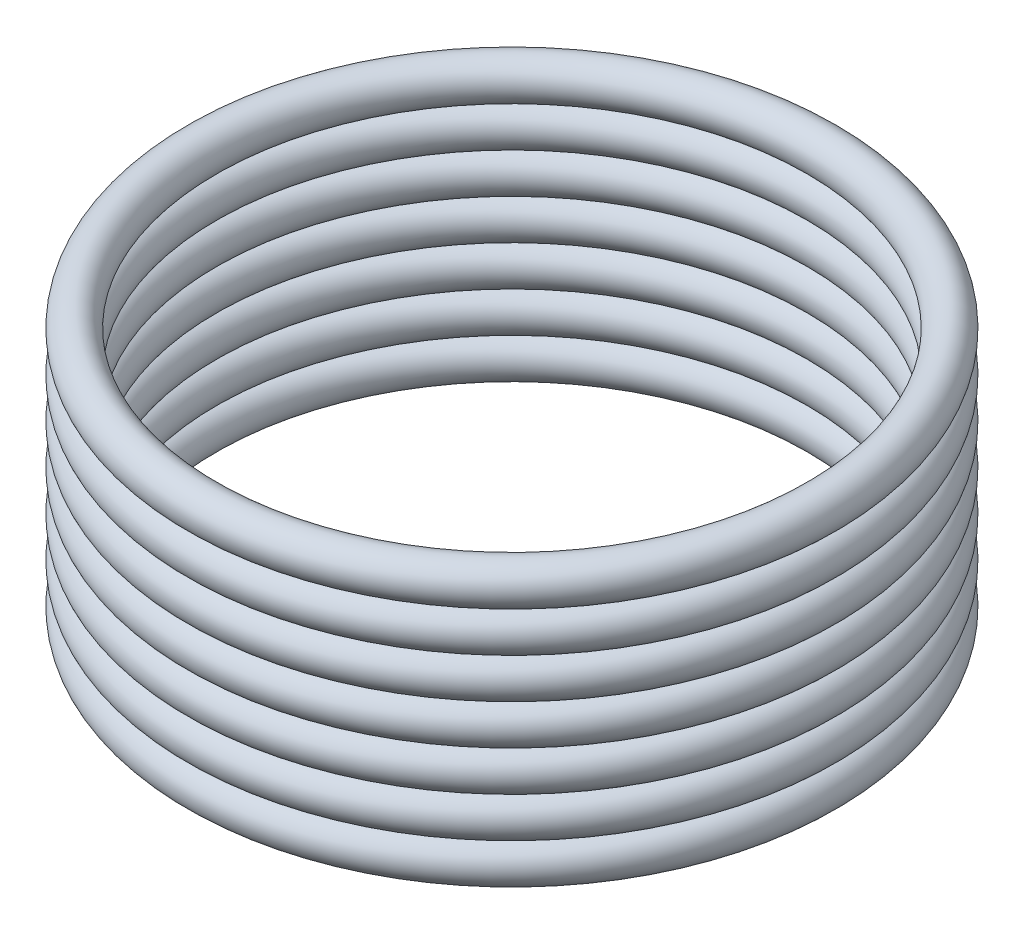
from build123d import *

# Parameters (mm, degrees)
SKETCH_1_R = 7
SKETCH_2_R = 7
SKETCH_3_R = 7
SKETCH_4_R = 7
SKETCH_5_R = 7
SKETCH_6_R = 7
SKETCH_7_R = 7


with BuildPart() as part:
    # 草图1 → 旋转1 (revolve)
    with BuildSketch(Plane.XY):
        with Locations((108, 0)):
            Circle(SKETCH_1_R)
    revolve(axis=Axis((0, 0, 0), (0, 1, 0)))


with BuildPart() as body_2:
    # 草图2 → 旋转2 (revolve)
    with BuildSketch(Plane.XY):
        with Locations((108, 14)):
            Circle(SKETCH_2_R)
    revolve(axis=Axis((0, 0, 0), (0, 1, 0)))


with BuildPart() as body_3:
    # 草图3 → 旋转3 (revolve)
    with BuildSketch(Plane.XY):
        with Locations((108, 28)):
            Circle(SKETCH_3_R)
    revolve(axis=Axis((0, 0, 0), (0, 1, 0)))


with BuildPart() as body_4:
    # 草图4 → 旋转4 (revolve)
    with BuildSketch(Plane.XY):
        with Locations((108, 42)):
            Circle(SKETCH_4_R)
    revolve(axis=Axis((0, 0, 0), (0, 1, 0)))


with BuildPart() as body_5:
    # 草图5 → 旋转5 (revolve)
    with BuildSketch(Plane.XY):
        with Locations((108, 56)):
            Circle(SKETCH_5_R)
    revolve(axis=Axis((0, 0, 0), (0, 1, 0)))


with BuildPart() as body_6:
    # 草图6 → 旋转6 (revolve)
    with BuildSketch(Plane.XY):
        with Locations((108, 70)):
            Circle(SKETCH_6_R)
    revolve(axis=Axis((0, 0, 0), (0, 1, 0)))


with BuildPart() as body_7:
    # 草图7 → 旋转7 (revolve)
    with BuildSketch(Plane.XY):
        with Locations((108, 84)):
            Circle(SKETCH_7_R)
    revolve(axis=Axis((0, 0, 0), (0, 1, 0)))


solid = Compound([part.part, body_2.part, body_3.part, body_4.part, body_5.part, body_6.part, body_7.part])
